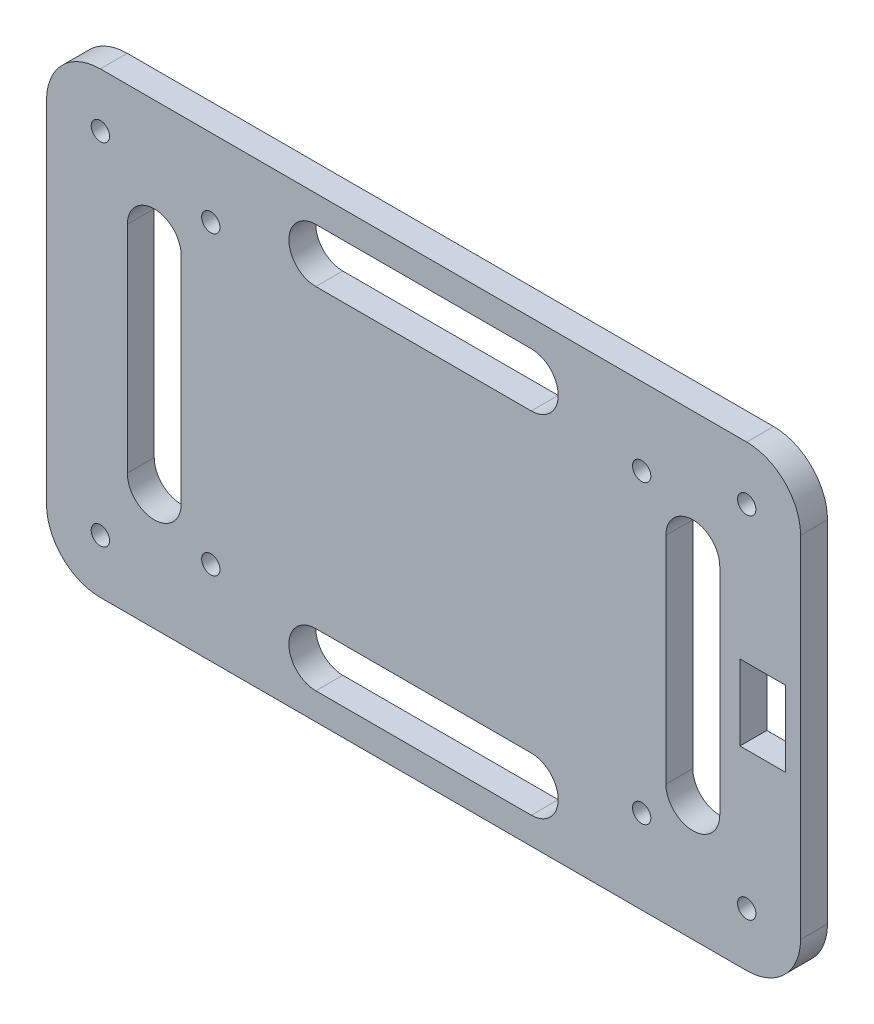
from build123d import *

# Parameters (mm, degrees)
BOSS_EXTRUDE1_DEPTH = 5
SKETCH2_R           = 1.7
SKETCH2_W           = 8.5
SKETCH2_H           = 14
CUT_EXTRUDE9_DEPTH  = 5


with BuildPart() as part:
    # Sketch1 → Boss-Extrude1 (new body)
    with BuildSketch(Plane.XY):
        with BuildLine():
            Line((-60, -42.5), (60, -42.5))
            ThreePointArc((60, -42.5), (67.071067812, -39.571067812), (70, -32.5))
            Line((70, -32.5), (70, 32.5))
            ThreePointArc((70, 32.5), (67.071067812, 39.571067812), (60, 42.5))
            Line((60, 42.5), (-60, 42.5))
            ThreePointArc((-60, 42.5), (-67.071067812, 39.571067812), (-70, 32.5))
            Line((-70, 32.5), (-70, -32.5))
            ThreePointArc((-70, -32.5), (-67.071067812, -39.571067812), (-60, -42.5))
        make_face()
    extrude(amount=BOSS_EXTRUDE1_DEPTH)

    # Sketch2 → Cut-Extrude9 (cut)
    with BuildSketch(Plane.XY):
        with BuildLine():
            Line((25, 32.5), (-25, 32.5))
            ThreePointArc((-25, 32.5), (-23.535533906, 28.964466094), (-20, 27.5))
            Line((-20, 27.5), (20, 27.5))
            ThreePointArc((20, 27.5), (23.535533906, 28.964466094), (25, 32.5))
        make_face()
        with BuildLine():
            ThreePointArc((-20, 37.5), (-23.535533906, 36.035533906), (-25, 32.5))
            Line((-25, 32.5), (25, 32.5))
            ThreePointArc((25, 32.5), (23.535533906, 36.035533906), (20, 37.5))
            Line((20, 37.5), (-20, 37.5))
        make_face()
        with BuildLine():
            Line((45, 20), (45, -20))
            ThreePointArc((45, -20), (50, -25), (55, -20))
            Line((55, -20), (55, 20))
            ThreePointArc((55, 20), (50, 25), (45, 20))
        make_face()
        with BuildLine():
            ThreePointArc((60, 34.2), (58.797918472, 31.297918472), (61.7, 32.5))
            Line((61.7, 32.5), (60, 32.5))
            Line((60, 32.5), (60, 34.2))
        make_face()
        with BuildLine():
            Line((60, 32.5), (61.7, 32.5))
            ThreePointArc((61.7, 32.5), (61.202081528, 33.702081528), (60, 34.2))
            Line((60, 34.2), (60, 32.5))
        make_face()
        with BuildLine():
            ThreePointArc((60, -34.2), (61.202081528, -33.702081528), (61.7, -32.5))
            Line((61.7, -32.5), (60, -32.5))
            Line((60, -32.5), (60, -34.2))
        make_face()
        with BuildLine():
            Line((60, -32.5), (61.7, -32.5))
            ThreePointArc((61.7, -32.5), (58.797918472, -31.297918472), (60, -34.2))
            Line((60, -34.2), (60, -32.5))
        make_face()
        with Locations((40.5, -26.9)):
            Circle(SKETCH2_R)
        with BuildLine():
            ThreePointArc((-20, -27.5), (-23.535533906, -28.964466094), (-25, -32.5))
            Line((-25, -32.5), (25, -32.5))
            ThreePointArc((25, -32.5), (23.535533906, -28.964466094), (20, -27.5))
            Line((20, -27.5), (-20, -27.5))
        make_face()
        with BuildLine():
            Line((25, -32.5), (-25, -32.5))
            ThreePointArc((-25, -32.5), (-23.535533906, -36.035533906), (-20, -37.5))
            Line((-20, -37.5), (20, -37.5))
            ThreePointArc((20, -37.5), (23.535533906, -36.035533906), (25, -32.5))
        make_face()
        with Locations((-39.5, -26.9)):
            Circle(SKETCH2_R)
        with BuildLine():
            ThreePointArc((-37.8, 28.1), (-38.297918472, 29.302081528), (-39.5, 29.8))
            Line((-39.5, 29.8), (-39.5, 28.1))
            Line((-39.5, 28.1), (-41.2, 28.1))
            ThreePointArc((-41.2, 28.1), (-39.5, 26.4), (-37.8, 28.1))
        make_face()
        with BuildLine():
            Line((-39.5, 28.1), (-39.5, 29.8))
            ThreePointArc((-39.5, 29.8), (-40.702081528, 29.302081528), (-41.2, 28.1))
            Line((-41.2, 28.1), (-39.5, 28.1))
        make_face()
        with BuildLine():
            Line((-55, 20), (-55, -20))
            ThreePointArc((-55, -20), (-50, -25), (-45, -20))
            Line((-45, -20), (-45, 20))
            ThreePointArc((-45, 20), (-50, 25), (-55, 20))
        make_face()
        with BuildLine():
            ThreePointArc((-60, 34.2), (-61.202081528, 33.702081528), (-61.7, 32.5))
            Line((-61.7, 32.5), (-60, 32.5))
            Line((-60, 32.5), (-60, 34.2))
        make_face()
        with BuildLine():
            Line((-60, 32.5), (-61.7, 32.5))
            ThreePointArc((-61.7, 32.5), (-60, 30.8), (-58.3, 32.5))
            ThreePointArc((-58.3, 32.5), (-58.797918472, 33.702081528), (-60, 34.2))
            Line((-60, 34.2), (-60, 32.5))
        make_face()
        with BuildLine():
            ThreePointArc((-58.3, -32.5), (-60, -30.8), (-61.7, -32.5))
            Line((-61.7, -32.5), (-60, -32.5))
            Line((-60, -32.5), (-60, -34.2))
            ThreePointArc((-60, -34.2), (-58.797918472, -33.702081528), (-58.3, -32.5))
        make_face()
        with BuildLine():
            Line((-60, -32.5), (-61.7, -32.5))
            ThreePointArc((-61.7, -32.5), (-61.202081528, -33.702081528), (-60, -34.2))
            Line((-60, -34.2), (-60, -32.5))
        make_face()
        with Locations((40.5, 28.1)):
            Circle(SKETCH2_R)
        with Locations((62.995775603, 0)):
            Rectangle(SKETCH2_W, SKETCH2_H)
    extrude(amount=CUT_EXTRUDE9_DEPTH, mode=Mode.SUBTRACT)


solid = part.part
